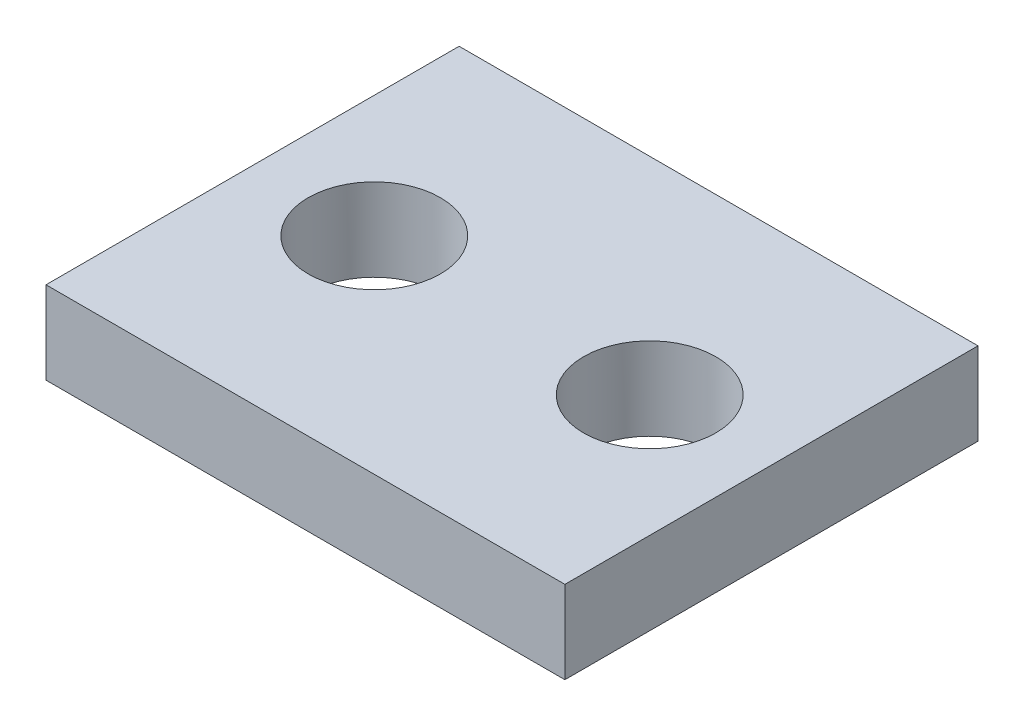
from build123d import *

# Parameters (mm, degrees)
SKETCH1_W           = 18.84
SKETCH1_H           = 15
BOSS_EXTRUDE1_DEPTH = 3
CUT_EXTRUDE1_START  = -4
SKETCH2_R           = 2.4
CUT_EXTRUDE1_DEPTH  = 5


with BuildPart() as part:
    # Sketch1 → Boss-Extrude1 (new body)
    with BuildSketch(Plane(origin=(0, 0, 0), x_dir=(1, 0, 0), z_dir=(0, 1, 0))):
        Rectangle(SKETCH1_W, SKETCH1_H)
    extrude(amount=BOSS_EXTRUDE1_DEPTH)

    # Sketch2 → Cut-Extrude1 (cut)
    with BuildSketch(Plane(origin=(0, 3, 0), x_dir=(1, 0, 0), z_dir=(0, 1, 0)).offset(CUT_EXTRUDE1_START)):
        with Locations((-5, 0)):
            Circle(SKETCH2_R)
    cut_extrude1 = extrude(amount=CUT_EXTRUDE1_DEPTH, mode=Mode.SUBTRACT)

    # Mirror1: Cut-Extrude1 across plane
    add(cut_extrude1.mirror(Plane(origin=(0, 0, 0), x_dir=(0, 0, 1), z_dir=(1, 0, 0))), mode=Mode.SUBTRACT)


solid = part.part
